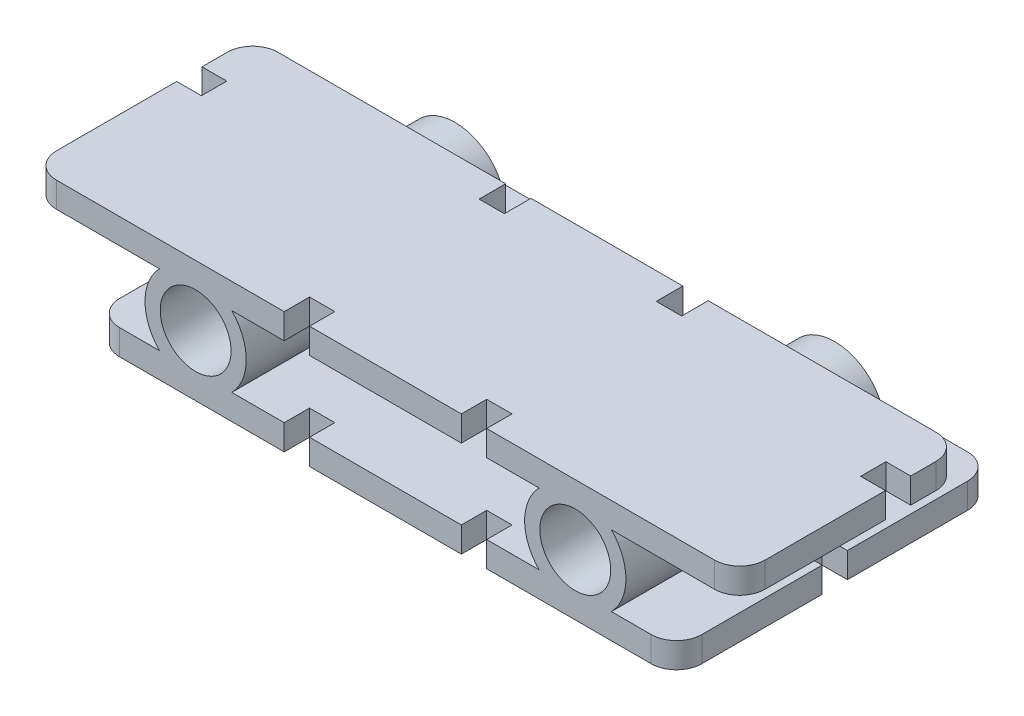
from build123d import *

# Parameters (mm, degrees)
SKETCH1_W           = 58.42
SKETCH1_H           = 31.75
BOSS_EXTRUDE1_DEPTH = 2.54
FILLET1_R           = 2.54
SKETCH4_R           = 5.08
BOSS_EXTRUDE3_DEPTH = 15.875
SKETCH5_R           = 5.08
BOSS_EXTRUDE4_DEPTH = 10.16
SKETCH6_R           = 3.556
CUT_EXTRUDE2_DEPTH  = 32.75
SKETCH9_W           = 13.97
SKETCH9_H           = 3.81
CUT_EXTRUDE4_DEPTH  = 1.27
SKETCH10_W          = 2.54
SKETCH10_H          = 2.54
SKETCH10_W_2        = 20.32
SKETCH10_H_2        = 3.81
CUT_EXTRUDE6_DEPTH  = 12.176
SKETCH11_W          = 71.12
SKETCH11_H          = 2.54
BOSS_EXTRUDE5_DEPTH = 15.875
SKETCH12_W          = 71.12
SKETCH12_H          = 2.54
BOSS_EXTRUDE6_DEPTH = 6.35
FILLET2_R           = 2.54
SKETCH13_W          = 2.54
SKETCH13_H          = 2.54
CUT_EXTRUDE7_DEPTH  = 2.54
SKETCH14_W          = 2.54
SKETCH14_H          = 2.54
SKETCH14_W_2        = 2.546026668
CUT_EXTRUDE8_DEPTH  = 13.192


with BuildPart() as part:
    # Sketch1 → Boss-Extrude1 (new body)
    with BuildSketch(Plane(origin=(0, 0, 0), x_dir=(1, 0, 0), z_dir=(0, 1, 0))):
        Rectangle(SKETCH1_W, SKETCH1_H)
    extrude(amount=BOSS_EXTRUDE1_DEPTH)

    # Fillet1
    fillet1_edges = [part.edges().sort_by_distance(p)[0] for p in [
        (29.21, 1.27, 15.875),
        (-29.21, 1.27, 15.875),
        (-29.21, 1.27, -15.875),
        (29.21, 1.27, -15.875),
    ]]
    fillet(fillet1_edges, radius=FILLET1_R)

    # Sketch4 → Boss-Extrude3 (add)
    with BuildSketch(Plane.XY):
        with Locations((-19.05, 6.096)):
            Circle(SKETCH4_R)
        with Locations((19.05, 6.096)):
            Circle(SKETCH4_R)
    extrude(amount=BOSS_EXTRUDE3_DEPTH)

    # Sketch5 → Boss-Extrude4 (add)
    with BuildSketch(Plane(origin=(0, 0, 0), x_dir=(-1, 0, 0), z_dir=(0, 0, -1))):
        with Locations((-19.05, 6.096)):
            Circle(SKETCH5_R)
        with Locations((19.05, 6.096)):
            Circle(SKETCH5_R)
    extrude(amount=BOSS_EXTRUDE4_DEPTH)

    # Sketch6 → Cut-Extrude2 (cut, through all)
    with BuildSketch(Plane.XY.offset(15.875)):
        with Locations((-19.05, 6.096)):
            Circle(SKETCH6_R)
        with Locations((19.05, 6.096)):
            Circle(SKETCH6_R)
    extrude(amount=-CUT_EXTRUDE2_DEPTH, mode=Mode.SUBTRACT)

    # Sketch9 → Cut-Extrude4 (cut)
    with BuildSketch(Plane(origin=(0, 2.54, 0), x_dir=(1, 0, 0), z_dir=(0, 1, 0))):
        with Locations((-6.985, 13.97)):
            Rectangle(SKETCH9_W, SKETCH9_H)
        with Locations((6.985, 13.97)):
            Rectangle(SKETCH9_W, SKETCH9_H)
    extrude(amount=-CUT_EXTRUDE4_DEPTH, mode=Mode.SUBTRACT)

    # Sketch10 → Cut-Extrude6 (cut, through all)
    with BuildSketch(Plane(origin=(0, 0, 0), x_dir=(1, 0, 0), z_dir=(0, 1, 0))):
        with Locations((-27.94, 0)):
            Rectangle(SKETCH10_W, SKETCH10_H)
        with Locations((27.94, 0)):
            Rectangle(SKETCH10_W, SKETCH10_H)
        with Locations((0, 13.97)):
            Rectangle(SKETCH10_W_2, SKETCH10_H_2)
        with Locations((-8.89, -14.605)):
            Rectangle(SKETCH10_W, SKETCH10_H)
        with Locations((8.89, -14.605)):
            Rectangle(SKETCH10_W, SKETCH10_H)
    extrude(amount=CUT_EXTRUDE6_DEPTH, mode=Mode.SUBTRACT)

    # Sketch11 → Boss-Extrude5 (add)
    with BuildSketch(Plane.XY):
        with Locations((0, 10.922)):
            Rectangle(SKETCH11_W, SKETCH11_H)
    extrude(amount=BOSS_EXTRUDE5_DEPTH)

    # Sketch12 → Boss-Extrude6 (add)
    with BuildSketch(Plane(origin=(0, 0, 0), x_dir=(-1, 0, 0), z_dir=(0, 0, -1))):
        with Locations((0, 10.922)):
            Rectangle(SKETCH12_W, SKETCH12_H)
    extrude(amount=BOSS_EXTRUDE6_DEPTH)

    # Fillet2
    fillet2_edges = [part.edges().sort_by_distance(p)[0] for p in [
        (-35.56, 10.922, 15.875),
        (35.56, 10.922, 15.875),
        (-35.56, 10.922, -6.35),
        (35.56, 10.922, -6.35),
    ]]
    fillet(fillet2_edges, radius=FILLET2_R)

    # Sketch13 → Cut-Extrude7 (cut)
    with BuildSketch(Plane(origin=(0, 12.192, 0), x_dir=(1, 0, 0), z_dir=(0, 1, 0))):
        with Locations((-34.344972833, 0.003915147)):
            Rectangle(SKETCH13_W, SKETCH13_H)
        with Locations((8.89, -14.605)):
            Rectangle(SKETCH13_W, SKETCH13_H)
        with Locations((-8.89, -14.605)):
            Rectangle(SKETCH13_W, SKETCH13_H)
        with Locations((34.344972833, 0.003915147)):
            Rectangle(SKETCH13_W, SKETCH13_H)
        with Locations((8.89, 4.953)):
            Rectangle(SKETCH13_W, SKETCH13_H)
        with Locations((-8.89, 4.953)):
            Rectangle(SKETCH13_W, SKETCH13_H)
    extrude(amount=-CUT_EXTRUDE7_DEPTH, mode=Mode.SUBTRACT)

    # Sketch14 → Cut-Extrude8 (cut, through all)
    with BuildSketch(Plane(origin=(0, 0, -3.683), x_dir=(-1, 0, 0), z_dir=(0, 0, -1))):
        with Locations((8.89, 10.922)):
            Rectangle(SKETCH14_W, SKETCH14_H)
        with Locations((-8.893013334, 10.922)):
            Rectangle(SKETCH14_W_2, SKETCH14_H)
    extrude(amount=CUT_EXTRUDE8_DEPTH, mode=Mode.SUBTRACT)


solid = part.part
